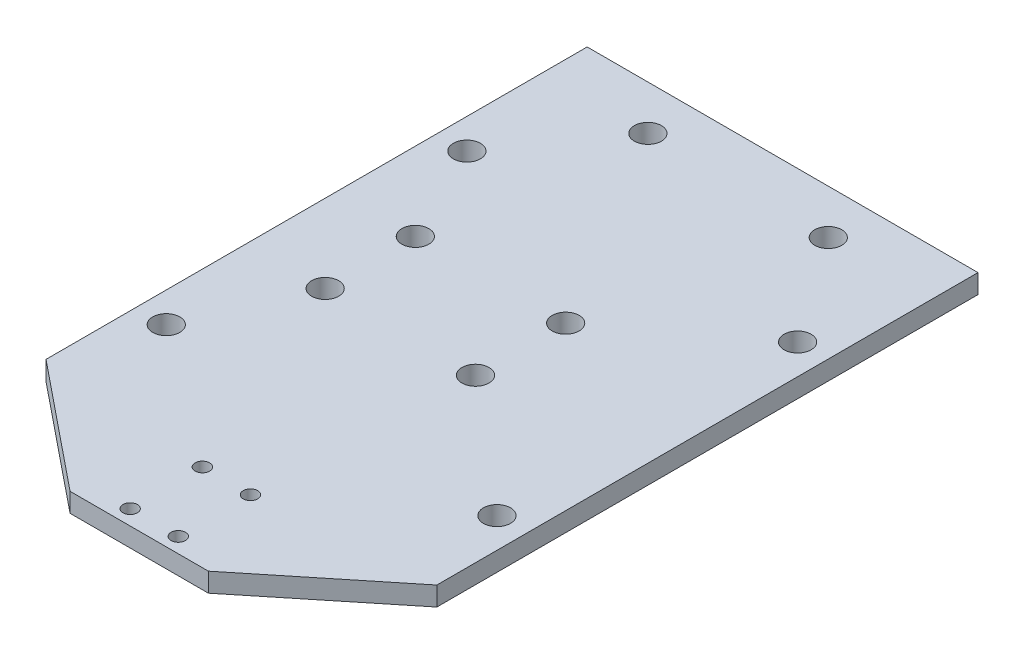
from build123d import *

# Parameters (mm, degrees)
SKETCH1_W            = 65
SKETCH1_H            = 90
SKETCH1_W_2          = 23
SKETCH1_H_2          = 17
BOSS_EXTRUDE1_DEPTH  = 1.5875
M2_CLEARANCE_HOLE1_D = 2.4
M4_CLEARANCE_HOLE1_D = 4.5
M4_CLEARANCE_HOLE2_D = 4.5
M4_CLEARANCE_HOLE3_D = 4.5


with BuildPart() as part:
    # Sketch1 → Boss-Extrude1 (new body, symmetric)
    with BuildSketch(Plane(origin=(0, 0, 0), x_dir=(1, 0, 0), z_dir=(0, 1, 0))):
        Polygon((-32.5, -45), (-11.5, -62), (-11.5, -45), align=None)
        Polygon((11.5, -45), (11.5, -62), (32.5, -45), align=None)
        Rectangle(SKETCH1_W, SKETCH1_H)
        with Locations((0, -53.5)):
            Rectangle(SKETCH1_W_2, SKETCH1_H_2)
    extrude(amount=BOSS_EXTRUDE1_DEPTH, both=True)

    # M2 Clearance Hole1 (through all)
    with Locations(Plane(origin=(0, 1.5875, 0), x_dir=(1, 0, 0), z_dir=(0, 1, 0))):
        with Locations((-4, -59.5), (4, -59.5), (4, -47.5), (-4, -47.5)):
            Hole(M2_CLEARANCE_HOLE1_D / 2)

    # M4 Clearance Hole1 (through all)
    with Locations(Plane(origin=(0, 1.5875, 0), x_dir=(1, 0, 0), z_dir=(0, 1, 0))):
        with Locations((-27.5, 20), (27.5, 20), (27.5, -30), (-27.5, -30)):
            Hole(M4_CLEARANCE_HOLE1_D / 2)

    # M4 Clearance Hole2 (through all)
    with Locations(Plane(origin=(0, 1.5875, 0), x_dir=(1, 0, 0), z_dir=(0, 1, 0))):
        with Locations((-19.5, -11.575), (-19.5, 3.425), (5.5, 3.425), (5.5, -11.575)):
            Hole(M4_CLEARANCE_HOLE2_D / 2)

    # M4 Clearance Hole3 (through all)
    with Locations(Plane(origin=(0, -1.5875, 0), x_dir=(-1, 0, 0), z_dir=(0, -1, 0))):
        with Locations((-15, 37.6), (15, 37.6)):
            Hole(M4_CLEARANCE_HOLE3_D / 2)


solid = part.part
